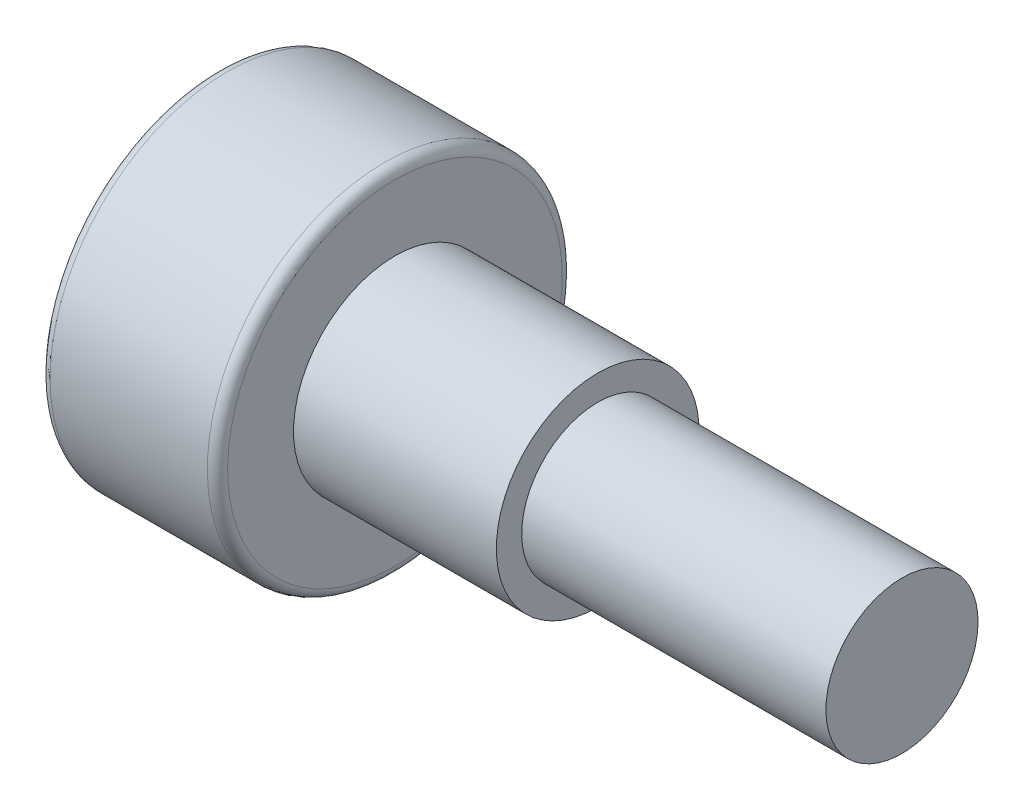
from build123d import *

# Parameters (mm, degrees)
CUT_EXTRUDE_1_DEPTH = 2
FILLET_1_R          = 0.2


with BuildPart() as part:
    # 草图1 → 旋转1 (revolve)
    with BuildSketch(Plane.XY):
        Polygon((0, 0), (0, 3.5), (3.5, 3.5), (3.5, 2), (7.5, 2), (7.5, 1.5), (13.5, 1.5), (13.5, 0), align=None)
    revolve(axis=Axis((13.5, 0, 0), (-1, 0, 0)))

    # 草图2 → 切除-拉伸1 (cut)
    with BuildSketch(Plane.ZY):
        Polygon((1.5, 0.866025404), (0, 1.732050808), (-1.5, 0.866025404), (-1.5, -0.866025404), (0, -1.732050808), (1.5, -0.866025404), align=None)
    extrude(amount=-CUT_EXTRUDE_1_DEPTH, mode=Mode.SUBTRACT)

    # 圆角1
    fillet_1_edges = [part.edges().sort_by_distance(p)[0] for p in [
        (3.5, -3.5, 0),
        (0, -3.5, 0),
    ]]
    fillet(fillet_1_edges, radius=FILLET_1_R)


solid = part.part
